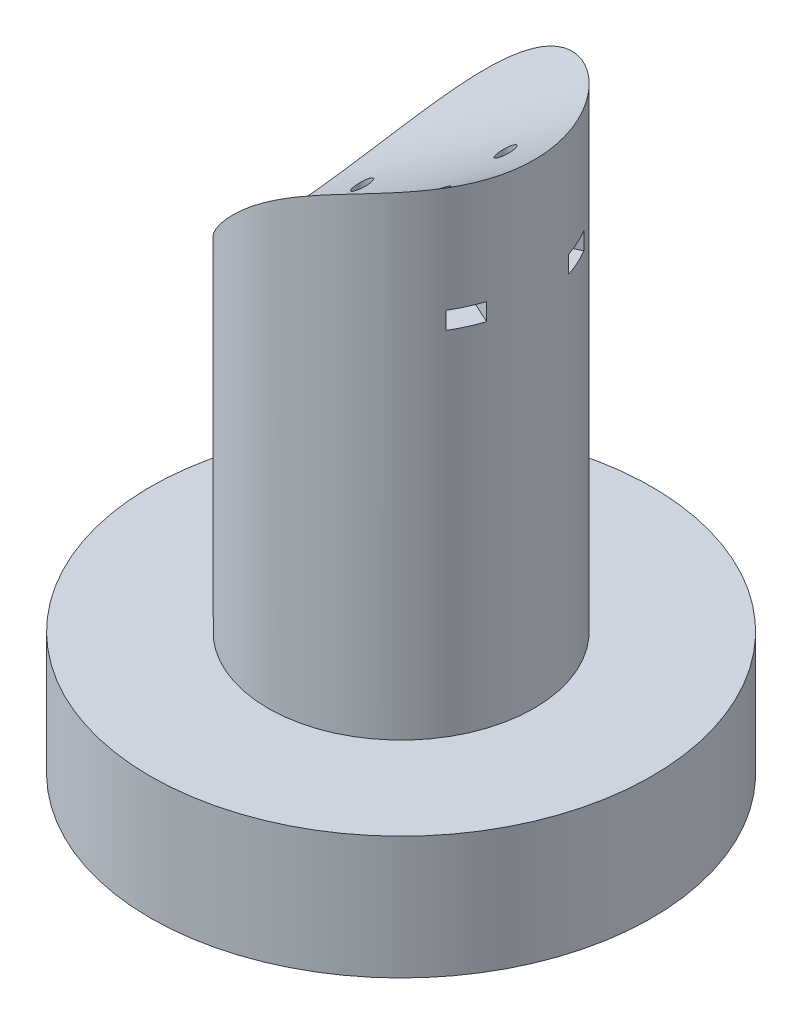
from build123d import *

# Parameters (mm, degrees)
SKETCH3_R               = 61.25
BOSS_EXTRUDE1_DEPTH     = 30
SKETCH4_R               = 32.5
BOSS_EXTRUDE2_DEPTH     = 134
CUT_EXTRUDE2_DEPTH      = 20
SKETCH10_R              = 52
CUT_EXTRUDE3_DEPTH      = 250
CUT_EXTRUDE4_DEPTH      = 3.5
SKETCH12_R              = 2
CUT_EXTRUDE5_DEPTH      = 167.901814071
CUT_EXTRUDE5_DEPTH_BACK = 29
CUT_EXTRUDE7_DEPTH      = 2.5
CUT_EXTRUDE7_DEPTH_BACK = 1.75
CUT_EXTRUDE8_REACH      = 171.791
CUT_EXTRUDE8_END_RADIUS = 84
SKETCH16_R              = 2
CUT_EXTRUDE9_DEPTH      = 4.25
CUT_EXTRUDE10_DEPTH     = 4.25


with BuildPart() as part:
    # Sketch3 → Boss-Extrude1 (new body)
    with BuildSketch(Plane(origin=(0, 0, 0), x_dir=(1, 0, 0), z_dir=(0, 1, 0))):
        with Locations(Location((0, 0, 0), (0, 0, 270))):
            Circle(SKETCH3_R)
    extrude(amount=-BOSS_EXTRUDE1_DEPTH)

    # Sketch4 → Boss-Extrude2 (add)
    with BuildSketch(Plane(origin=(0, 0, 0), x_dir=(1, 0, 0), z_dir=(0, 1, 0))):
        with Locations(Location((0, 0, 0), (0, 0, 270))):
            Circle(SKETCH4_R)
    extrude(amount=BOSS_EXTRUDE2_DEPTH)

    # Sketch7 → Cut-Extrude2 (cut)
    with BuildSketch(Plane.XZ.offset(30)):
        with BuildLine():
            Line((-16.761190292, 10.75), (-23.304288773, 10.75))
            ThreePointArc((-23.304288773, 10.75), (-26.38740479, 9.686292116), (-28.158706882, 6.947758249))
            ThreePointArc((-28.158706882, 6.947758249), (-29.003174274, 0), (-28.158706882, -6.947758249))
            ThreePointArc((-28.158706882, -6.947758249), (-26.38740479, -9.686292116), (-23.304288773, -10.75))
            Line((-23.304288773, -10.75), (-16.761190292, -10.75))
            ThreePointArc((-16.761190292, -10.75), (-14.776192208, -11.160906123), (-13.117453272, -12.326086957))
            ThreePointArc((-13.117453272, -12.326086957), (18, 0), (-13.117453272, 12.326086957))
            ThreePointArc((-13.117453272, 12.326086957), (-14.776192208, 11.160906123), (-16.761190292, 10.75))
        make_face()
    extrude(amount=-CUT_EXTRUDE2_DEPTH, mode=Mode.SUBTRACT)

    # Sketch10 → Cut-Extrude3 (cut)
    with BuildSketch(Plane(origin=(-62.5, 34.5, 0), x_dir=(0, 0, -1), z_dir=(0.8191520442889949, 0.5735764363510418, 0))):
        with Locations((0, 64.298335316)):
            Circle(SKETCH10_R)
    extrude(amount=CUT_EXTRUDE3_DEPTH, mode=Mode.SUBTRACT)

    # Sketch11 → Cut-Extrude4 (cut)
    with BuildSketch(Plane.XZ.offset(30)):
        with BuildLine():
            Line((-17.177810632, 20.75), (-12.833062768, 20.75))
            ThreePointArc((-12.833062768, 20.75), (-10.358189034, 19.724873734), (-9.333062768, 17.25))
            Line((-9.333062768, 17.25), (-9.333062768, 15.391359244))
            ThreePointArc((-9.333062768, 15.391359244), (-18, 0), (-9.333062768, -15.391359244))
            Line((-9.333062768, -15.391359244), (-9.333062768, -17.25))
            ThreePointArc((-9.333062768, -17.25), (-10.358189034, -19.724873734), (-12.833062768, -20.75))
            Line((-12.833062768, -20.75), (-17.177810632, -20.75))
            ThreePointArc((-17.177810632, -20.75), (-20.209263922, -20.059539678), (-22.642689151, -18.124368843))
            ThreePointArc((-22.642689151, -18.124368843), (-29.003174274, 0), (-22.642689151, 18.124368843))
            ThreePointArc((-22.642689151, 18.124368843), (-20.209263922, 20.059539678), (-17.177810632, 20.75))
        make_face()
    extrude(amount=-CUT_EXTRUDE4_DEPTH, mode=Mode.SUBTRACT)

    # Sketch12 → Cut-Extrude5 (cut, two sides)
    with BuildSketch(Plane.XZ.offset(26.5)) as cut_extrude5_sk:
        with Locations(Location((-17.177810632, 15.391359244, 0), (0, 0, 90))):
            Circle(SKETCH12_R)
        with Locations(Location((-17.177810632, -15.391359244, 0), (0, 0, 90))):
            Circle(SKETCH12_R)
    extrude(amount=CUT_EXTRUDE5_DEPTH, mode=Mode.SUBTRACT)
    extrude(cut_extrude5_sk.sketch, amount=-CUT_EXTRUDE5_DEPTH_BACK, mode=Mode.SUBTRACT)

    # Sketch13 → Cut-Extrude7 (cut, two sides)
    with BuildSketch(Plane.XZ.offset(-2.5)) as cut_extrude7_sk:
        with BuildLine():
            Line((-13.952849981, -12.501786819), (-18.067773433, -11.153675181))
            Line((-18.067773433, -11.153675181), (-21.292734084, -14.043247606))
            Line((-21.292734084, -14.043247606), (-48.034197532, -38.003662554))
            ThreePointArc((-48.034197532, -38.003662554), (-45.617331549, -40.873237728), (-43.029311279, -43.589458253))
            Line((-43.029311279, -43.589458253), (-16.287847832, -19.629043306))
            Line((-16.287847832, -19.629043306), (-13.062887181, -16.739470881))
            Line((-13.062887181, -16.739470881), (-13.952849981, -12.501786819))
        make_face()
        with BuildLine():
            Line((-21.292734084, 14.043247606), (-48.034197532, 38.003662554))
            ThreePointArc((-48.034197532, 38.003662554), (-45.617331549, 40.873237728), (-43.029311279, 43.589458253))
            Line((-43.029311279, 43.589458253), (-16.287847832, 19.629043306))
            Line((-16.287847832, 19.629043306), (-13.062887181, 16.739470881))
            Line((-13.062887181, 16.739470881), (-13.952849981, 12.501786819))
            Line((-13.952849981, 12.501786819), (-18.067773433, 11.153675181))
            Line((-18.067773433, 11.153675181), (-21.292734084, 14.043247606))
        make_face()
    extrude(amount=CUT_EXTRUDE7_DEPTH, mode=Mode.SUBTRACT)
    extrude(cut_extrude7_sk.sketch, amount=-CUT_EXTRUDE7_DEPTH_BACK, mode=Mode.SUBTRACT)

    # Cut-Extrude8: up to this cylinder (the profile starts inside it)
    cut_extrude8_end = Plane(origin=(-19.133802192, 143.359112462, 0), z_dir=(-0.8191520442889949, -0.5735764363510418, 0)) * Cylinder(CUT_EXTRUDE8_END_RADIUS, 541.25232155, mode=Mode.PRIVATE)
    # Sketch16 → Cut-Extrude8 (cut, up to the surface)
    with BuildSketch(Plane(origin=(0, 116.033211368, 0), x_dir=(-1, 0, 0), z_dir=(0, -1, 0)), mode=Mode.PRIVATE) as cut_extrude8_sk1:
        with Locations(Location((-17.5, 8, 0), (0, 0, 270))):
            Circle(SKETCH16_R)
    cut_extrude8_tool1 = extrude(cut_extrude8_sk1.sketch, amount=CUT_EXTRUDE8_REACH, mode=Mode.PRIVATE) & cut_extrude8_end
    add(cut_extrude8_tool1.solids().sort_by_distance((17.5, 116.033211, -8))[0], mode=Mode.SUBTRACT)
    # Sketch16 → Cut-Extrude8 (cut, up to the surface)
    with BuildSketch(Plane(origin=(0, 116.033211368, 0), x_dir=(-1, 0, 0), z_dir=(0, -1, 0)), mode=Mode.PRIVATE) as cut_extrude8_sk2:
        with Locations(Location((17.5, 8, 0), (0, 0, 270))):
            Circle(SKETCH16_R)
    cut_extrude8_tool2 = extrude(cut_extrude8_sk2.sketch, amount=CUT_EXTRUDE8_REACH, mode=Mode.PRIVATE) & cut_extrude8_end
    add(cut_extrude8_tool2.solids().sort_by_distance((-17.5, 116.033211, -8))[0], mode=Mode.SUBTRACT)
    # Sketch16 → Cut-Extrude8 (cut, up to the surface)
    with BuildSketch(Plane(origin=(0, 116.033211368, 0), x_dir=(-1, 0, 0), z_dir=(0, -1, 0)), mode=Mode.PRIVATE) as cut_extrude8_sk3:
        with Locations(Location((17.5, -8, 0), (0, 0, 270))):
            Circle(SKETCH16_R)
    cut_extrude8_tool3 = extrude(cut_extrude8_sk3.sketch, amount=CUT_EXTRUDE8_REACH, mode=Mode.PRIVATE) & cut_extrude8_end
    add(cut_extrude8_tool3.solids().sort_by_distance((-17.5, 116.033211, 8))[0], mode=Mode.SUBTRACT)
    # Sketch16 → Cut-Extrude8 (cut, up to the surface)
    with BuildSketch(Plane(origin=(0, 116.033211368, 0), x_dir=(-1, 0, 0), z_dir=(0, -1, 0)), mode=Mode.PRIVATE) as cut_extrude8_sk4:
        with Locations(Location((-17.5, -8, 0), (0, 0, 270))):
            Circle(SKETCH16_R)
    cut_extrude8_tool4 = extrude(cut_extrude8_sk4.sketch, amount=CUT_EXTRUDE8_REACH, mode=Mode.PRIVATE) & cut_extrude8_end
    add(cut_extrude8_tool4.solids().sort_by_distance((17.5, 116.033211, 8))[0], mode=Mode.SUBTRACT)

    # Sketch17 → Cut-Extrude9 (cut)
    with BuildSketch(Plane(origin=(0, 56.033211368, 0), x_dir=(-1, 0, 0), z_dir=(0, -1, 0))):
        Polygon((13.56186, -6.199707429), (13.971830899, -10.510382998), (17.909970899, -12.310675569), (27.998821356, -16.922721492), (31.117019558, -10.101662925), (21.028169101, -5.489617002), (17.090029101, -3.689324431), align=None)
        Polygon((27.998821356, 16.922721492), (17.909970899, 12.310675569), (13.971830899, 10.510382998), (13.56186, 6.199707429), (17.090029101, 3.689324431), (21.028169101, 5.489617002), (31.117019558, 10.101662925), align=None)
    extrude(amount=-CUT_EXTRUDE9_DEPTH, mode=Mode.SUBTRACT)

    # Sketch18 → Cut-Extrude10 (cut)
    with BuildSketch(Plane(origin=(0, 86.033211368, 0), x_dir=(-1, 0, 0), z_dir=(0, -1, 0))):
        Polygon((-31.117019558, -10.101662925), (-21.028169101, -5.489617002), (-17.090029101, -3.689324431), (-13.56186, -6.199707429), (-13.971830899, -10.510382998), (-17.909970899, -12.310675569), (-27.998821356, -16.922721492), align=None)
        Polygon((-31.117019558, 10.101662925), (-27.998821356, 16.922721492), (-17.909970899, 12.310675569), (-13.971830899, 10.510382998), (-13.56186, 6.199707429), (-17.090029101, 3.689324431), (-21.028169101, 5.489617002), align=None)
    extrude(amount=-CUT_EXTRUDE10_DEPTH, mode=Mode.SUBTRACT)


solid = part.part
